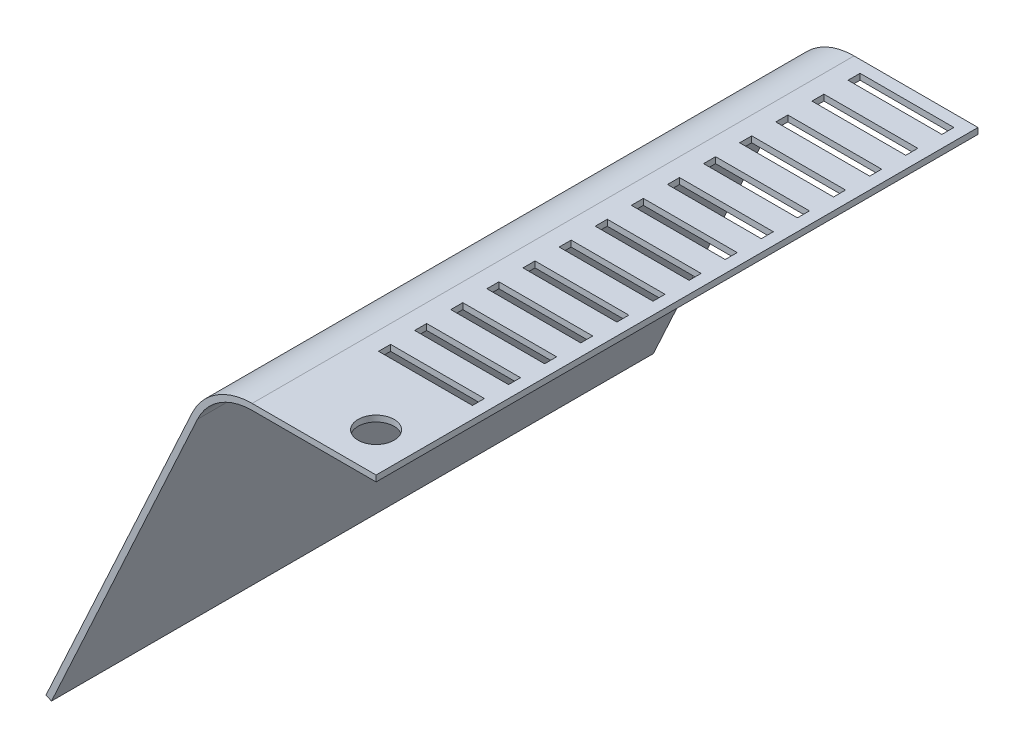
from build123d import *

# Parameters (mm, degrees)
EXTRUDE_THIN1_DEPTH = 500
SKETCH2_W           = 155.95
SKETCH2_H           = 20
CUT_EXTRUDE1_DEPTH  = 596.0316925
LPATTERN1_COUNT     = 14
LPATTERN1_PITCH     = 60
SKETCH3_R           = 30
CUT_EXTRUDE2_DEPTH  = 596.0316925


with BuildPart() as part:
    # Sketch1 → Extrude-Thin1 (new body, symmetric)
    with BuildSketch(Plane.XY):
        with BuildLine():
            Line((0, 0), (-205.95, 0))
            ThreePointArc((-205.95, 0), (-259.885879639, -15.792394123), (-296.786225905, -58.181582248))
            Line((-296.786225905, -58.181582248), (-539.333048865, -585.0316925))
            Line((-539.333048865, -585.0316925), (-548.416671455, -580.849850725))
            Line((-548.416671455, -580.849850725), (-305.869848496, -53.999740473))
            ThreePointArc((-305.869848496, -53.999740473), (-265.279467603, -7.371633535), (-205.95, 10))
            Line((-205.95, 10), (0, 10))
            Line((0, 10), (0, 0))
        make_face()
    extrude(amount=EXTRUDE_THIN1_DEPTH, both=True)

    # Sketch2 → Cut-Extrude1 (cut, through all)
    with BuildSketch(Plane(origin=(0, 10, 0), x_dir=(1, 0, 0), z_dir=(0, 1, 0))):
        with Locations((-97.975, 470)):
            Rectangle(SKETCH2_W, SKETCH2_H)
    cut_extrude1 = extrude(amount=-CUT_EXTRUDE1_DEPTH, mode=Mode.SUBTRACT)

    # LPattern1: Cut-Extrude1 ×14
    with Locations(*[(0, 0, i * LPATTERN1_PITCH) for i in range(1, LPATTERN1_COUNT)]):
        add(cut_extrude1, mode=Mode.SUBTRACT)

    # Sketch3 → Cut-Extrude2 (cut, through all)
    with BuildSketch(Plane(origin=(0, 10, 0), x_dir=(1, 0, 0), z_dir=(0, 1, 0))):
        with Locations((-65, -435)):
            Circle(SKETCH3_R)
    extrude(amount=-CUT_EXTRUDE2_DEPTH, mode=Mode.SUBTRACT)


solid = part.part
